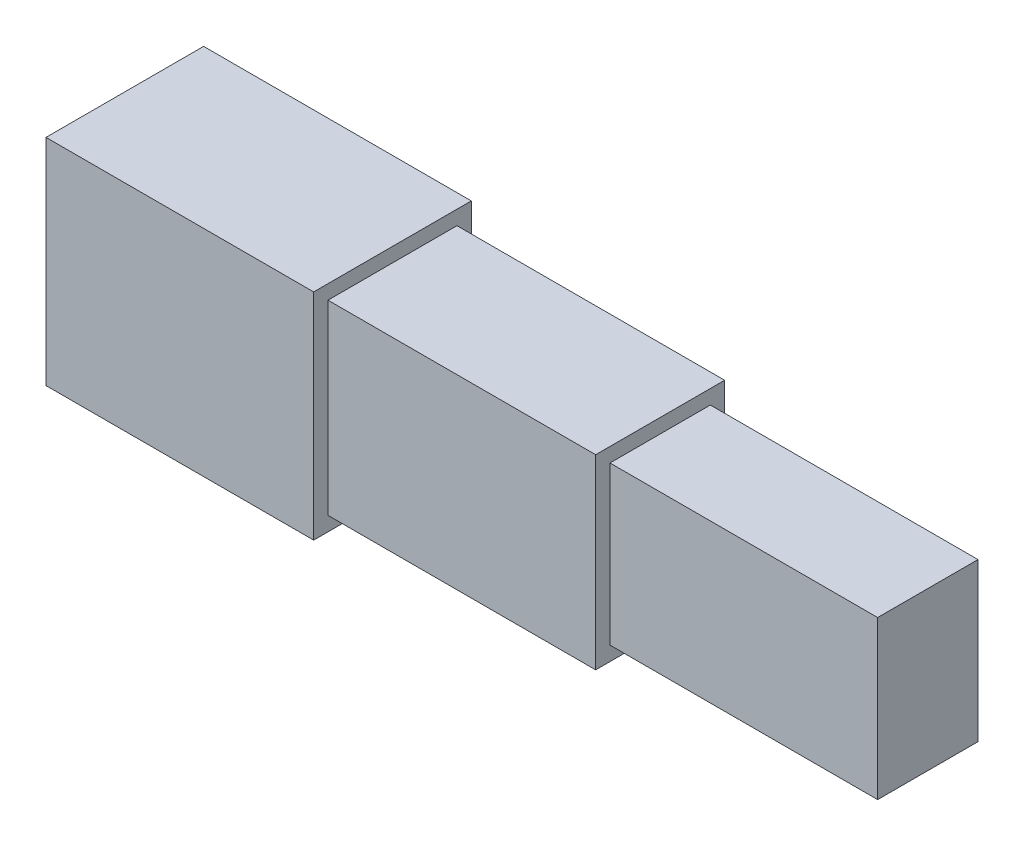
from build123d import *

# Parameters (mm, degrees)
SKETCH1_W           = 549.631
SKETCH1_H           = 749.631
BOSS_EXTRUDE1_DEPTH = 933.333333333
SKETCH2_W           = 449.8
SKETCH2_H           = 649.8
BOSS_EXTRUDE2_DEPTH = 933.333333333
SKETCH3_W           = 349.969
SKETCH3_H           = 549.969
BOSS_EXTRUDE3_DEPTH = 933.333333333


with BuildPart() as part:
    # Sketch1 → Boss-Extrude1 (new body)
    with BuildSketch(Plane(origin=(0, 0, 0), x_dir=(0, 0, -1), z_dir=(1, 0, 0))):
        Rectangle(SKETCH1_W, SKETCH1_H)
    extrude(amount=BOSS_EXTRUDE1_DEPTH)

    # Sketch2 → Boss-Extrude2 (add)
    with BuildSketch(Plane(origin=(933.333333333, 0, 0), x_dir=(0, 0, -1), z_dir=(1, 0, 0))):
        Rectangle(SKETCH2_W, SKETCH2_H)
    extrude(amount=BOSS_EXTRUDE2_DEPTH)

    # Sketch3 → Boss-Extrude3 (add)
    with BuildSketch(Plane(origin=(1866.666666667, 0, 0), x_dir=(0, 0, -1), z_dir=(1, 0, 0))):
        Rectangle(SKETCH3_W, SKETCH3_H)
    extrude(amount=BOSS_EXTRUDE3_DEPTH)


solid = part.part
